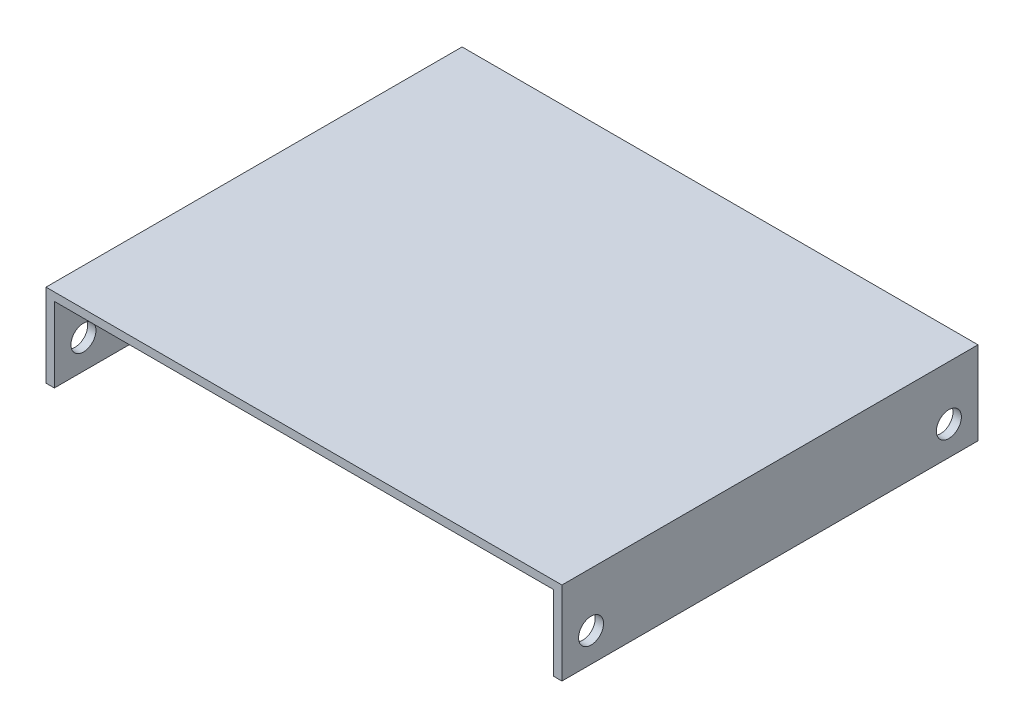
from build123d import *

# Parameters (mm, degrees)
BOSS_EXTRUDE1_DEPTH = 100
SKETCH2_R           = 3
CUT_EXTRUDE1_DEPTH  = 141
SKETCH3_R           = 3
CUT_EXTRUDE2_DEPTH  = 141


with BuildPart() as part:
    # Sketch1 → Boss-Extrude1 (new body)
    with BuildSketch(Plane.XY):
        Polygon((0, 0), (0, 20), (124, 20), (124, 0), (122, 0), (122, 18.041941508), (2, 18.041941508), (2, 0), align=None)
    extrude(amount=BOSS_EXTRUDE1_DEPTH)

    # Sketch2 → Cut-Extrude1 (cut)
    with BuildSketch(Plane(origin=(124, 0, 0), x_dir=(0, 0, -1), z_dir=(1, 0, 0))):
        with Locations((-93, 7)):
            Circle(SKETCH2_R)
    extrude(amount=-CUT_EXTRUDE1_DEPTH, mode=Mode.SUBTRACT)

    # Sketch3 → Cut-Extrude2 (cut)
    with BuildSketch(Plane(origin=(124, 0, 0), x_dir=(0, 0, -1), z_dir=(1, 0, 0))):
        with Locations((-7, 7)):
            Circle(SKETCH3_R)
    extrude(amount=-CUT_EXTRUDE2_DEPTH, mode=Mode.SUBTRACT)


solid = part.part
